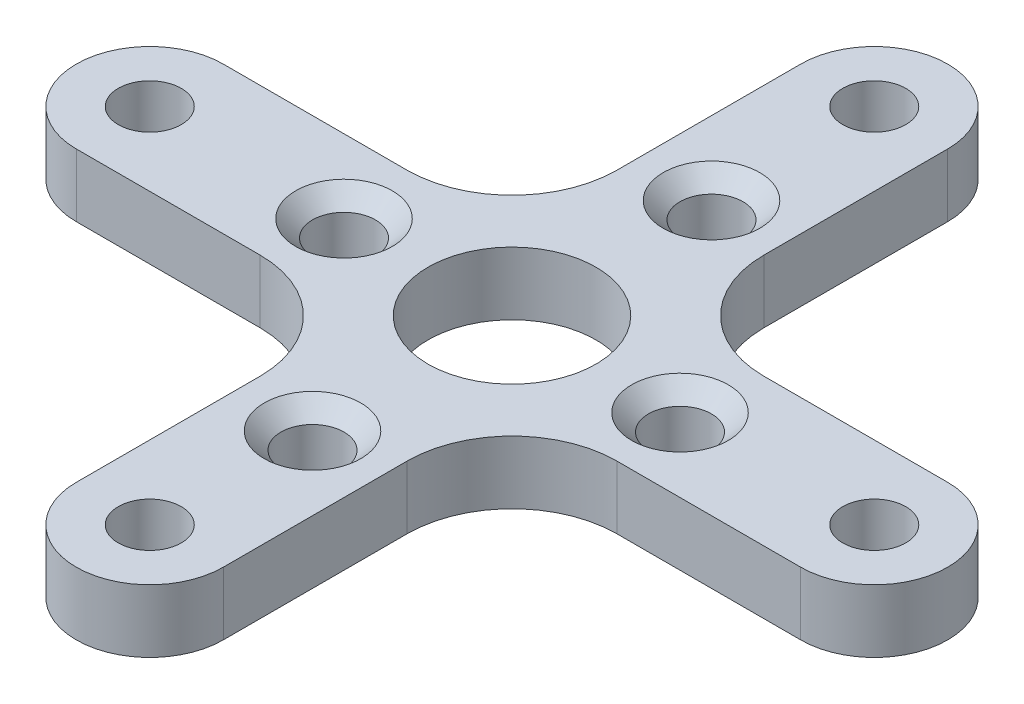
from build123d import *

# Parameters (mm, degrees)
SKETCH1_R           = 4
SKETCH1_R_2         = 1.5
BOSS_EXTRUDE1_DEPTH = 3
CHAMFER1_SIZE       = 0.8


with BuildPart() as part:
    # Sketch1 → Boss-Extrude1 (new body)
    with BuildSketch(Plane(origin=(0, 0, 0), x_dir=(1, 0, 0), z_dir=(0, 1, 0))):
        with BuildLine():
            Line((-3.5, 17.25), (-3.5, 8.5))
            ThreePointArc((-3.5, 8.5), (-4.964466094, 4.964466094), (-8.5, 3.5))
            Line((-8.5, 3.5), (-17.25, 3.5))
            ThreePointArc((-17.25, 3.5), (-20.75, 0), (-17.25, -3.5))
            Line((-17.25, -3.5), (-8.5, -3.5))
            ThreePointArc((-8.5, -3.5), (-4.964466094, -4.964466094), (-3.5, -8.5))
            Line((-3.5, -8.5), (-3.5, -17.25))
            ThreePointArc((-3.5, -17.25), (0, -20.75), (3.5, -17.25))
            Line((3.5, -17.25), (3.5, -8.5))
            ThreePointArc((3.5, -8.5), (4.964466094, -4.964466094), (8.5, -3.5))
            Line((8.5, -3.5), (17.25, -3.5))
            ThreePointArc((17.25, -3.5), (20.75, 0), (17.25, 3.5))
            Line((17.25, 3.5), (8.5, 3.5))
            ThreePointArc((8.5, 3.5), (4.964466094, 4.964466094), (3.5, 8.5))
            Line((3.5, 8.5), (3.5, 17.25))
            ThreePointArc((3.5, 17.25), (0, 20.75), (-3.5, 17.25))
        make_face()
        Circle(SKETCH1_R, mode=Mode.SUBTRACT)
        with Locations((0, 17.25)):
            Circle(SKETCH1_R_2, mode=Mode.SUBTRACT)
        with Locations((17.25, 0)):
            Circle(SKETCH1_R_2, mode=Mode.SUBTRACT)
        with Locations((0, -17.25)):
            Circle(SKETCH1_R_2, mode=Mode.SUBTRACT)
        with Locations((-17.25, 0)):
            Circle(SKETCH1_R_2, mode=Mode.SUBTRACT)
        with Locations((-8, 0)):
            Circle(SKETCH1_R_2, mode=Mode.SUBTRACT)
        with Locations((8, 0)):
            Circle(SKETCH1_R_2, mode=Mode.SUBTRACT)
        with Locations((0, 9.5)):
            Circle(SKETCH1_R_2, mode=Mode.SUBTRACT)
        with Locations((0, -9.5)):
            Circle(SKETCH1_R_2, mode=Mode.SUBTRACT)
    extrude(amount=BOSS_EXTRUDE1_DEPTH)

    # Chamfer1
    chamfer1_edges = [part.edges().sort_by_distance(p)[0] for p in [
        (-9.5, 3, 0),
        (6.5, 3, 0),
        (-1.5, 3, -9.5),
        (-1.5, 3, 9.5),
    ]]
    chamfer(chamfer1_edges, length=CHAMFER1_SIZE)


solid = part.part
